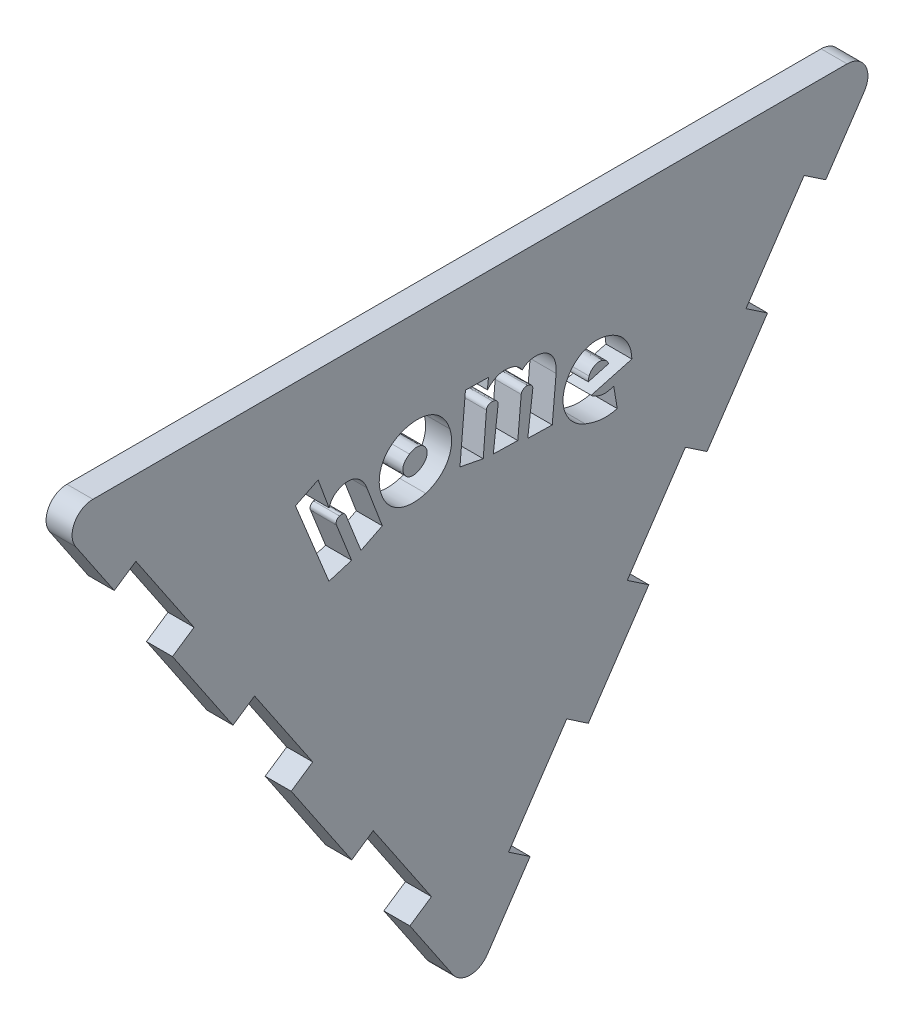
from build123d import *

# Parameters (mm, degrees)
EXTRUDE1_DEPTH     = 3.175
CUT_EXTRUDE1_DEPTH = 4.175
CUT_EXTRUDE2_DEPTH = 4.175


with BuildPart() as part:
    # Sketch1 → Extrude1 (new body)
    with BuildSketch(Plane(origin=(0, 0, 0), x_dir=(0, 0, -1), z_dir=(1, 0, 0))):
        with BuildLine():
            Line((-2.105755434, 3.121910816), (-48.128710212, 71.353747226))
            ThreePointArc((-48.128710212, 71.353747226), (-48.265641664, 73.96655497), (-46.022954778, 75.3140972))
            Line((-46.022954778, 75.3140972), (46.022954778, 75.3140972))
            ThreePointArc((46.022954778, 75.3140972), (48.265641664, 73.96655497), (48.128710212, 71.353747226))
            Line((48.128710212, 71.353747226), (2.105755434, 3.121910816))
            ThreePointArc((2.105755434, 3.121910816), (0, 2.002260791), (-2.105755434, 3.121910816))
        make_face()
    extrude(amount=EXTRUDE1_DEPTH)

    # Sketch2 → Cut-Extrude1 (cut, through all)
    with BuildSketch(Plane(origin=(3.175, 0, 0), x_dir=(0, 0, -1), z_dir=(1, 0, 0))):
        Polygon((-43.414180131, 64.364168942), (-40.781985838, 66.139606411), (-33.680235964, 55.610829239), (-36.312430257, 53.835391771), align=None)
        Polygon((-28.926610388, 42.885463512), (-21.824860514, 32.356686341), (-19.192666221, 34.132123809), (-26.294416095, 44.660900981), align=None)
        Polygon((-11.806846352, 23.182195551), (-4.705096478, 12.65341838), (-7.337290771, 10.877980911), (-14.439040645, 21.406758083), align=None)
        Polygon((4.705096478, 12.65341838), (7.337290771, 10.877980911), (14.439040645, 21.406758083), (11.806846352, 23.182195551), align=None)
        Polygon((28.926610388, 42.885463512), (26.294416095, 44.660900981), (19.192666221, 34.132123809), (21.824860514, 32.356686341), align=None)
        Polygon((43.414180131, 64.364168942), (36.312430257, 53.835391771), (33.680235964, 55.610829239), (40.781985838, 66.139606411), align=None)
    extrude(amount=-CUT_EXTRUDE1_DEPTH, mode=Mode.SUBTRACT)

    # Sketch3 → Cut-Extrude2 (cut, through all)
    with BuildSketch(Plane(origin=(3.175, 0, 0), x_dir=(0, 0, -1), z_dir=(1, 0, 0))):
        with BuildLine():
            Line((-18.538789786, 63.621277359), (-21.306595982, 62.256304541))
            Line((-21.306595982, 62.256304541), (-17.217655511, 52.243182771))
            Line((-17.217655511, 52.243182771), (-14.447856653, 53.076115089))
            Line((-14.447856653, 53.076115089), (-16.295053445, 57.719015333))
            add(Edge.make_bspline(
                [(-16.295053445, 57.719015333), (-16.309628512, 57.760402158), (-16.337539428, 57.839656966), (-16.346919652, 57.963133227), (-16.331902897, 58.081456258), (-16.286231613, 58.191568768), (-16.220290113, 58.290883593), (-16.137194867, 58.377641876), (-16.038705305, 58.451292064), (-15.96306235, 58.484940887), (-15.92441849, 58.502131125)],
                knots=[0, 0, 0, 0, 0.000131123, 0.000251097, 0.000367765, 0.000485804, 0.000605181, 0.000723573, 0.000844732, 0.000971278, 0.000971278, 0.000971278, 0.000971278], degree=3))
            add(Edge.make_bspline(
                [(-15.92441849, 58.502131125), (-15.882941496, 58.516083169), (-15.803310416, 58.542869496), (-15.681686317, 58.560389959), (-15.56519626, 58.550287037), (-15.456808745, 58.514990497), (-15.357588686, 58.46296645), (-15.274832924, 58.390457892), (-15.203558515, 58.305703682), (-15.172976042, 58.238039419), (-15.157243986, 58.203231968)],
                knots=[0, 0, 0, 0, 0.000131123, 0.00025174, 0.000365758, 0.000478568, 0.0005918, 0.000699219, 0.000806896, 0.000920966, 0.000920966, 0.000920966, 0.000920966], degree=3))
            Line((-15.157243986, 58.203231968), (-13.306061872, 53.548375758))
            Line((-13.306061872, 53.548375758), (-10.703646543, 54.847590762))
            Line((-10.703646543, 54.847590762), (-12.592689217, 59.813302095))
            add(Edge.make_bspline(
                [(-12.592689217, 59.813302095), (-12.627986955, 59.901508386), (-12.697284686, 60.074678008), (-12.821244216, 60.322462168), (-12.965209083, 60.550615982), (-13.122829474, 60.762719579), (-13.292668827, 60.955671536), (-13.47600424, 61.125659127), (-13.666822238, 61.277237854), (-13.871708669, 61.402334969), (-14.084524408, 61.507061526), (-14.307887403, 61.585525054), (-14.540637677, 61.637277793), (-14.781936984, 61.663453199), (-15.031229443, 61.660634127), (-15.286783088, 61.631299569), (-15.547988488, 61.568585432), (-15.719091029, 61.505530399), (-15.806851488, 61.473188748)],
                knots=[0, 0, 0, 0, 0.000284951, 0.000559425, 0.000829788, 0.001093219, 0.001351536, 0.001599669, 0.001842422, 0.002081317, 0.002318377, 0.002552817, 0.002789701, 0.0030322, 0.003279298, 0.003536104, 0.003802414, 0.004082841, 0.004082841, 0.004082841, 0.004082841], degree=3))
            add(Edge.make_bspline(
                [(-15.806851488, 61.473188748), (-15.891354299, 61.437006352), (-16.056877107, 61.36613283), (-16.286994614, 61.233251889), (-16.495700601, 61.083465804), (-16.682627989, 60.915445668), (-16.846952063, 60.726758717), (-16.982552504, 60.511533677), (-17.098203853, 60.274228467), (-17.150863689, 60.102440499), (-17.17780229, 60.014560861)],
                knots=[0, 0, 0, 0, 0.000275571, 0.000539785, 0.000795289, 0.001045008, 0.001292267, 0.001543216, 0.001806141, 0.002081511, 0.002081511, 0.002081511, 0.002081511], degree=3))
            Line((-17.17780229, 60.014560861), (-17.203706883, 60.002604895))
            Line((-17.203706883, 60.002604895), (-18.538789786, 63.621277359))
        make_face()
        with BuildLine():
            add(Edge.make_bspline(
                [(-2.462660194, 60.970428343), (-2.513750123, 61.118940064), (-2.614066285, 61.410545982), (-2.808144904, 61.822343556), (-3.036549251, 62.200418519), (-3.298601983, 62.542466256), (-3.584287896, 62.852202684), (-3.896229573, 63.123289701), (-4.229279013, 63.357946434), (-4.585804488, 63.5512892), (-4.960232211, 63.706357209), (-5.349186174, 63.828072136), (-5.755910326, 63.903924349), (-6.174576465, 63.946720517), (-6.604163558, 63.947295568), (-7.040382848, 63.91202451), (-7.481794513, 63.834064087), (-7.773022514, 63.75326355), (-7.920558806, 63.712329946)],
                knots=[0, 0, 0, 0, 0.000470897, 0.000924616, 0.001362729, 0.001793554, 0.002215137, 0.002624725, 0.003031042, 0.003434983, 0.003838727, 0.004245273, 0.004655224, 0.005077753, 0.00550618, 0.005942058, 0.006389241, 0.006848388, 0.006848388, 0.006848388, 0.006848388], degree=3))
            add(Edge.make_bspline(
                [(-7.920558806, 63.712329946), (-8.066459112, 63.665418567), (-8.35398471, 63.572970355), (-8.761065684, 63.385815308), (-9.14462811, 63.174075752), (-9.496292726, 62.926241825), (-9.817423822, 62.65309046), (-10.10745102, 62.357495057), (-10.358786449, 62.035200753), (-10.57453477, 61.69108836), (-10.755410664, 61.327932609), (-10.893892022, 60.944883776), (-10.99902419, 60.545601457), (-11.063905837, 60.129812598), (-11.090084006, 59.699692445), (-11.061089728, 59.259717289), (-10.991105366, 58.809838955), (-10.906778782, 58.513403566), (-10.863719175, 58.362035031)],
                knots=[0, 0, 0, 0, 0.000459389, 0.000905318, 0.00134157, 0.001772211, 0.002193459, 0.002604933, 0.003012319, 0.003417021, 0.003821604, 0.004226958, 0.004636812, 0.005058438, 0.005487527, 0.005926677, 0.00637876, 0.006850483, 0.006850483, 0.006850483, 0.006850483], degree=3))
            add(Edge.make_bspline(
                [(-10.863719175, 58.362035031), (-10.815081613, 58.213350068), (-10.719654254, 57.921628751), (-10.525004974, 57.512534465), (-10.302647603, 57.133895444), (-10.04221, 56.793521478), (-9.755296217, 56.48815885), (-9.444423208, 56.219497576), (-9.112530954, 55.986639259), (-8.758079682, 55.7928357), (-8.383909689, 55.636973623), (-7.992450979, 55.519677736), (-7.584724508, 55.439525404), (-7.162398071, 55.398087237), (-6.729389234, 55.39609049), (-6.29034581, 55.435821265), (-5.846949444, 55.509247147), (-5.555299386, 55.590832192), (-5.407813224, 55.632089394)],
                knots=[0, 0, 0, 0, 0.000468881, 0.000919949, 0.00135601, 0.001784043, 0.002202715, 0.002610997, 0.003014539, 0.003416731, 0.003820474, 0.004228347, 0.004640636, 0.005065147, 0.005499552, 0.005937584, 0.006386389, 0.006845536, 0.006845536, 0.006845536, 0.006845536], degree=3))
            add(Edge.make_bspline(
                [(-5.407813224, 55.632089394), (-5.262662594, 55.679902004), (-4.976236428, 55.774250768), (-4.569175713, 55.960334192), (-4.186333572, 56.172574261), (-3.833354966, 56.418607061), (-3.511060963, 56.69071288), (-3.221501498, 56.986765232), (-2.970291794, 57.306886285), (-2.752934993, 57.647486881), (-2.574185774, 58.009437563), (-2.428929935, 58.389162857), (-2.326031581, 58.788387678), (-2.260198634, 59.203241141), (-2.234341099, 59.632796811), (-2.263397713, 60.072709423), (-2.332841708, 60.522918316), (-2.418763085, 60.819106317), (-2.462660194, 60.970428343)],
                knots=[0, 0, 0, 0, 0.00045816, 0.000904089, 0.001340341, 0.001769841, 0.00219261, 0.002604083, 0.003009902, 0.003411234, 0.003814033, 0.004218911, 0.004628765, 0.005048422, 0.005477511, 0.005916661, 0.006368745, 0.006840976, 0.006840976, 0.006840976, 0.006840976], degree=3))
        make_face()
        with BuildLine():
            add(Edge.make_bspline(
                [(-8.006243231, 58.882119564), (-8.050560588, 58.96153356), (-8.136486338, 59.115507252), (-8.200251808, 59.370521274), (-8.209945162, 59.628618736), (-8.154944031, 59.886727867), (-8.046504886, 60.138242591), (-7.879167842, 60.373462468), (-7.657281094, 60.589734782), (-7.480940085, 60.710080641), (-7.388518306, 60.7731549)],
                knots=[0, 0, 0, 0, 0.000271799, 0.000526984, 0.000780178, 0.001040447, 0.001311778, 0.001596478, 0.00190084, 0.00223604, 0.00223604, 0.00223604, 0.00223604], degree=3))
            add(Edge.make_bspline(
                [(-7.388518306, 60.7731549), (-7.293768379, 60.828727087), (-7.112441559, 60.935077861), (-6.826273972, 61.039320398), (-6.544992274, 61.084018508), (-6.273786821, 61.066915788), (-6.018450603, 61.00058827), (-5.787703286, 60.879246201), (-5.583480356, 60.709102545), (-5.477972943, 60.564503812), (-5.423754512, 60.490197031)],
                knots=[0, 0, 0, 0, 0.000329037, 0.000629691, 0.000907844, 0.001177325, 0.001439305, 0.00169332, 0.001953559, 0.002228662, 0.002228662, 0.002228662, 0.002228662], degree=3))
            add(Edge.make_bspline(
                [(-5.423754512, 60.490197031), (-5.378704563, 60.408825517), (-5.291682018, 60.251640961), (-5.227518305, 59.993748587), (-5.220854559, 59.73508038), (-5.274460795, 59.478097227), (-5.383438166, 59.229405282), (-5.547686997, 58.996555811), (-5.763668394, 58.78106633), (-5.937041551, 58.661544265), (-6.02753081, 58.599161695)],
                knots=[0, 0, 0, 0, 0.000278039, 0.000537085, 0.000788231, 0.0010485, 0.001318004, 0.001597154, 0.001898685, 0.002227885, 0.002227885, 0.002227885, 0.002227885], degree=3))
            add(Edge.make_bspline(
                [(-6.02753081, 58.599161695), (-6.124202854, 58.542690332), (-6.308655694, 58.434941465), (-6.599722346, 58.332291581), (-6.882361238, 58.282585977), (-7.112471727, 58.292026044), (-7.286091343, 58.329429979), (-7.409088098, 58.370595654), (-7.527591141, 58.419980968), (-7.634736608, 58.491383927), (-7.740137622, 58.567314917), (-7.835106203, 58.660960928), (-7.926344102, 58.764697443), (-7.979154529, 58.842309208), (-8.006243231, 58.882119564)],
                knots=[0, 0, 0, 0, 0.000335241, 0.000639649, 0.000920395, 0.001191661, 0.001324154, 0.001452073, 0.001580549, 0.001707705, 0.001837228, 0.001969707, 0.002106737, 0.002251051, 0.002251051, 0.002251051, 0.002251051], degree=3))
        make_face(mode=Mode.SUBTRACT)
        with BuildLine():
            Line((7.049075017, 55.216167632), (10.036073929, 55.144431834))
            Line((10.036073929, 55.144431834), (10.508334597, 60.351255154))
            add(Edge.make_bspline(
                [(10.508334597, 60.351255154), (10.514355398, 60.448186567), (10.526226634, 60.63930658), (10.520107193, 60.92384613), (10.492137752, 61.200236507), (10.444555781, 61.468162096), (10.376757618, 61.725438849), (10.290361782, 61.971167498), (10.179392773, 62.201468973), (10.049846181, 62.417302691), (9.900858531, 62.618077793), (9.727344081, 62.798403366), (9.534130099, 62.960243486), (9.31892126, 63.101023512), (9.082388614, 63.217897036), (8.826849258, 63.315056451), (8.54868561, 63.381997221), (8.355875741, 63.40837036), (8.256627612, 63.42194583)],
                knots=[0, 0, 0, 0, 0.000291263, 0.000574284, 0.000852665, 0.00112393, 0.001389762, 0.00165007, 0.001904085, 0.002155263, 0.002404346, 0.002652398, 0.002904216, 0.003159004, 0.003421891, 0.003694296, 0.003977507, 0.00427793, 0.00427793, 0.00427793, 0.00427793], degree=3))
            add(Edge.make_bspline(
                [(8.256627612, 63.42194583), (8.167018195, 63.428509919), (7.991109157, 63.441395647), (7.729262648, 63.427683931), (7.477345659, 63.381058007), (7.235113138, 63.30686283), (7.004021717, 63.207029879), (6.779527529, 63.093146318), (6.567610113, 62.953826329), (6.434595095, 62.849039601), (6.367584938, 62.796250261)],
                knots=[0, 0, 0, 0, 0.000269371, 0.000528792, 0.000784016, 0.001036149, 0.001287074, 0.001538402, 0.001790432, 0.002046301, 0.002046301, 0.002046301, 0.002046301], degree=3))
            add(Edge.make_bspline(
                [(6.367584938, 62.796250261), (6.315187784, 62.869737308), (6.212802792, 63.013332338), (6.039264716, 63.205426664), (5.851718722, 63.369001224), (5.649443497, 63.506869597), (5.426380973, 63.620954484), (5.175707414, 63.706833268), (4.898539208, 63.776074865), (4.702100476, 63.800055059), (4.600094588, 63.812507395)],
                knots=[0, 0, 0, 0, 0.000270606, 0.000528769, 0.000774522, 0.001015494, 0.001261456, 0.001523641, 0.001808786, 0.002116799, 0.002116799, 0.002116799, 0.002116799], degree=3))
            add(Edge.make_bspline(
                [(4.600094588, 63.812507395), (4.474614436, 63.822529369), (4.230807966, 63.842001947), (3.874224504, 63.81457106), (3.540086324, 63.746352856), (3.230415621, 63.627498302), (2.93908147, 63.471511553), (2.660812907, 63.28219096), (2.39261675, 63.061196281), (2.228603449, 62.892211071), (2.145136176, 62.806213566)],
                knots=[0, 0, 0, 0, 0.00037714, 0.000732778, 0.001068883, 0.001396795, 0.001723944, 0.002058313, 0.002405042, 0.002764346, 0.002764346, 0.002764346, 0.002764346], degree=3))
            Line((2.145136176, 62.806213566), (2.119231583, 62.808206227))
            Line((2.119231583, 62.808206227), (2.252739873, 64.063582687))
            Line((2.252739873, 64.063582687), (-0.556912206, 64.115391875))
            Line((-0.556912206, 64.115391875), (-1.224453657, 56.33405048))
            Line((-1.224453657, 56.33405048), (1.615088337, 55.782083369))
            Line((1.615088337, 55.782083369), (2.005649903, 60.721890109))
            add(Edge.make_bspline(
                [(2.005649903, 60.721890109), (2.01152284, 60.769480981), (2.022772601, 60.860642513), (2.073055185, 60.987173187), (2.156640721, 61.090425872), (2.265740396, 61.168250974), (2.386554943, 61.226180695), (2.512839462, 61.264906459), (2.640813527, 61.284528874), (2.726296441, 61.278733893), (2.768839084, 61.27584988)],
                knots=[0, 0, 0, 0, 0.000143485, 0.00027485, 0.000402443, 0.000536352, 0.0006736, 0.000802816, 0.000931601, 0.001059193, 0.001059193, 0.001059193, 0.001059193], degree=3))
            add(Edge.make_bspline(
                [(2.768839084, 61.27584988), (2.821059746, 61.26831527), (2.921420969, 61.253834743), (3.06029627, 61.204501306), (3.183848933, 61.139270268), (3.283589823, 61.050514219), (3.366904455, 60.951855046), (3.416579488, 60.837021488), (3.441080507, 60.7126366), (3.431434519, 60.628276026), (3.42641723, 60.584396497)],
                knots=[0, 0, 0, 0, 0.000157911, 0.000303485, 0.000439935, 0.000574155, 0.000701747, 0.000823951, 0.000945504, 0.001077261, 0.001077261, 0.001077261, 0.001077261], degree=3))
            Line((3.42641723, 60.584396497), (2.844560204, 55.664516367))
            Line((2.844560204, 55.664516367), (5.831559116, 55.59278057))
            Line((5.831559116, 55.59278057), (6.248025275, 60.269556051))
            add(Edge.make_bspline(
                [(6.248025275, 60.269556051), (6.25438015, 60.305902836), (6.267314379, 60.379880313), (6.317986043, 60.484289078), (6.389589218, 60.584410787), (6.483813021, 60.67562201), (6.59619495, 60.754381605), (6.727331199, 60.807312547), (6.872966589, 60.831462853), (6.973316249, 60.824909189), (7.025163084, 60.821523161)],
                knots=[0, 0, 0, 0, 0.000110229, 0.000224351, 0.000344341, 0.000478206, 0.00061583, 0.000753482, 0.000898933, 0.001054411, 0.001054411, 0.001054411, 0.001054411], degree=3))
            add(Edge.make_bspline(
                [(7.025163084, 60.821523161), (7.075404073, 60.814737806), (7.171154192, 60.801806163), (7.30334057, 60.753813385), (7.419636819, 60.69067188), (7.514681442, 60.606424702), (7.590071125, 60.510163003), (7.641558257, 60.402249711), (7.666020073, 60.283222198), (7.662589945, 60.20188382), (7.660821959, 60.159959693)],
                knots=[0, 0, 0, 0, 0.000151678, 0.000289071, 0.000419327, 0.000546421, 0.000667187, 0.000783957, 0.000901979, 0.001027517, 0.001027517, 0.001027517, 0.001027517], degree=3))
            Line((7.660821959, 60.159959693), (7.049075017, 55.216167632))
        make_face()
        with BuildLine():
            Line((17.971785121, 52.902312722), (17.539377674, 55.484801441))
            add(Edge.make_bspline(
                [(17.539377674, 55.484801441), (17.387483648, 55.437686579), (17.081764625, 55.3428579), (16.683235562, 55.273561033), (16.350284665, 55.258398648), (16.086114901, 55.29223848), (15.808930357, 55.355001707), (15.625730407, 55.423429681), (15.530775337, 55.458896848)],
                knots=[0, 0, 0, 0, 0.000476808, 0.000959678, 0.001208888, 0.001473613, 0.001755896, 0.002059645, 0.002059645, 0.002059645, 0.002059645], degree=3))
            add(Edge.make_bspline(
                [(15.530775337, 55.458896848), (15.464679325, 55.486763901), (15.325188543, 55.545575272), (15.123321131, 55.647412453), (14.935404615, 55.759381415), (14.837844101, 55.856922899), (14.793490749, 55.901267601)],
                knots=[0, 0, 0, 0, 0.000215078, 0.000453907, 0.000678875, 0.000866407, 0.000866407, 0.000866407, 0.000866407], degree=3))
            Line((14.793490749, 55.901267601), (19.753224099, 57.246313808))
            add(Edge.make_bspline(
                [(19.753224099, 57.246313808), (19.749557182, 57.350718267), (19.74229399, 57.557515874), (19.702573471, 57.863640356), (19.645440724, 58.162655939), (19.567523871, 58.454353614), (19.469533101, 58.737964894), (19.352161884, 59.014259518), (19.211229212, 59.281761044), (19.052651277, 59.541641911), (18.876739579, 59.791480291), (18.677202269, 60.023471918), (18.460933323, 60.24025181), (18.22529617, 60.440843879), (17.972608445, 60.627061997), (17.698179797, 60.793437894), (17.407024805, 60.946266638), (17.20262641, 61.03249294), (17.098999582, 61.076208344)],
                knots=[0, 0, 0, 0, 0.000313254, 0.000620473, 0.000924907, 0.001226036, 0.001525366, 0.001824432, 0.002125686, 0.002431552, 0.002737319, 0.003041205, 0.003348372, 0.003655068, 0.003968733, 0.004288957, 0.004616942, 0.00495422, 0.00495422, 0.00495422, 0.00495422], degree=3))
            add(Edge.make_bspline(
                [(17.098999582, 61.076208344), (16.967611435, 61.124497582), (16.707622066, 61.220051777), (16.307662723, 61.319087776), (15.906018801, 61.379354913), (15.504982945, 61.401709701), (15.107045635, 61.383995956), (14.716428982, 61.325914533), (14.334251858, 61.228190038), (13.963007878, 61.089221335), (13.602286086, 60.915411477), (13.26060206, 60.693796815), (12.930400151, 60.439519306), (12.619316981, 60.14311882), (12.328518395, 59.807844832), (12.068331858, 59.428520748), (11.832464742, 59.010302112), (11.704643084, 58.709641996), (11.639108309, 58.555492117)],
                knots=[0, 0, 0, 0, 0.0004197, 0.000830498, 0.001233488, 0.001636602, 0.002033547, 0.00242639, 0.002819313, 0.003214629, 0.003613878, 0.004017961, 0.004434084, 0.004862575, 0.005304789, 0.005763023, 0.006240306, 0.006742476, 0.006742476, 0.006742476, 0.006742476], degree=3))
            add(Edge.make_bspline(
                [(11.639108309, 58.555492117), (11.591749397, 58.428188891), (11.497946446, 58.176041662), (11.40805489, 57.783790036), (11.35455745, 57.3881459), (11.346434856, 56.990174659), (11.372412858, 56.595447187), (11.442639408, 56.209769593), (11.542667545, 55.832289758), (11.685510259, 55.467697896), (11.863359452, 55.116304597), (12.075518065, 54.779513285), (12.324366094, 54.459780711), (12.606607654, 54.157047694), (12.923751543, 53.877078629), (13.276304835, 53.627274486), (13.662965183, 53.408944567), (13.938127784, 53.289752073), (14.078125432, 53.229109134)],
                knots=[0, 0, 0, 0, 0.000407098, 0.000806332, 0.001204266, 0.001602923, 0.001998455, 0.002388961, 0.00277712, 0.003168261, 0.00356126, 0.003957093, 0.004360458, 0.004774951, 0.005197099, 0.00562726, 0.006068939, 0.00652641, 0.00652641, 0.00652641, 0.00652641], degree=3))
            add(Edge.make_bspline(
                [(14.078125432, 53.229109134), (14.250694341, 53.163730534), (14.586443443, 53.036530294), (15.090351881, 52.888412572), (15.576525093, 52.78370948), (16.050433659, 52.721911019), (16.520580405, 52.704455412), (16.996450726, 52.726761783), (17.483334503, 52.78987197), (17.80692182, 52.864361386), (17.971785121, 52.902312722)],
                knots=[0, 0, 0, 0, 0.000553465, 0.001076818, 0.001573946, 0.002044045, 0.002508682, 0.002983441, 0.003471838, 0.003979126, 0.003979126, 0.003979126, 0.003979126], degree=3))
        make_face()
        with BuildLine():
            Line((16.913682105, 58.176886518), (14.438797082, 57.495396439))
            add(Edge.make_bspline(
                [(14.438797082, 57.495396439), (14.435654882, 57.534528678), (14.429536611, 57.610724221), (14.42877517, 57.708520468), (14.442952693, 57.792333047), (14.46338296, 57.86947274), (14.493933892, 57.96172028), (14.518890438, 58.027538409), (14.532452151, 58.063304838)],
                knots=[0, 0, 0, 0, 0.000117837, 0.000229444, 0.000292015, 0.000372242, 0.000468655, 0.000583402, 0.000583402, 0.000583402, 0.000583402], degree=3))
            add(Edge.make_bspline(
                [(14.532452151, 58.063304838), (14.569014812, 58.141843992), (14.641932303, 58.298475864), (14.79875223, 58.507346448), (14.986825236, 58.685841142), (15.201626042, 58.828603625), (15.435749465, 58.931015106), (15.685678071, 58.978679928), (15.945479378, 58.974179391), (16.110189557, 58.919953193), (16.194331466, 58.892251835)],
                knots=[0, 0, 0, 0, 0.000259329, 0.000517185, 0.000777949, 0.001033834, 0.001287372, 0.001539047, 0.001792241, 0.002056665, 0.002056665, 0.002056665, 0.002056665], degree=3))
            add(Edge.make_bspline(
                [(16.194331466, 58.892251835), (16.278313928, 58.854723307), (16.438388128, 58.783192313), (16.614082101, 58.654768795), (16.732137793, 58.536775213), (16.805833932, 58.431303675), (16.868447712, 58.310733005), (16.898255133, 58.222534218), (16.913682105, 58.176886518)],
                knots=[0, 0, 0, 0, 0.00027537, 0.000524866, 0.00064746, 0.000774631, 0.000909206, 0.001053574, 0.001053574, 0.001053574, 0.001053574], degree=3))
        make_face(mode=Mode.SUBTRACT)
    extrude(amount=-CUT_EXTRUDE2_DEPTH, mode=Mode.SUBTRACT)


solid = part.part
